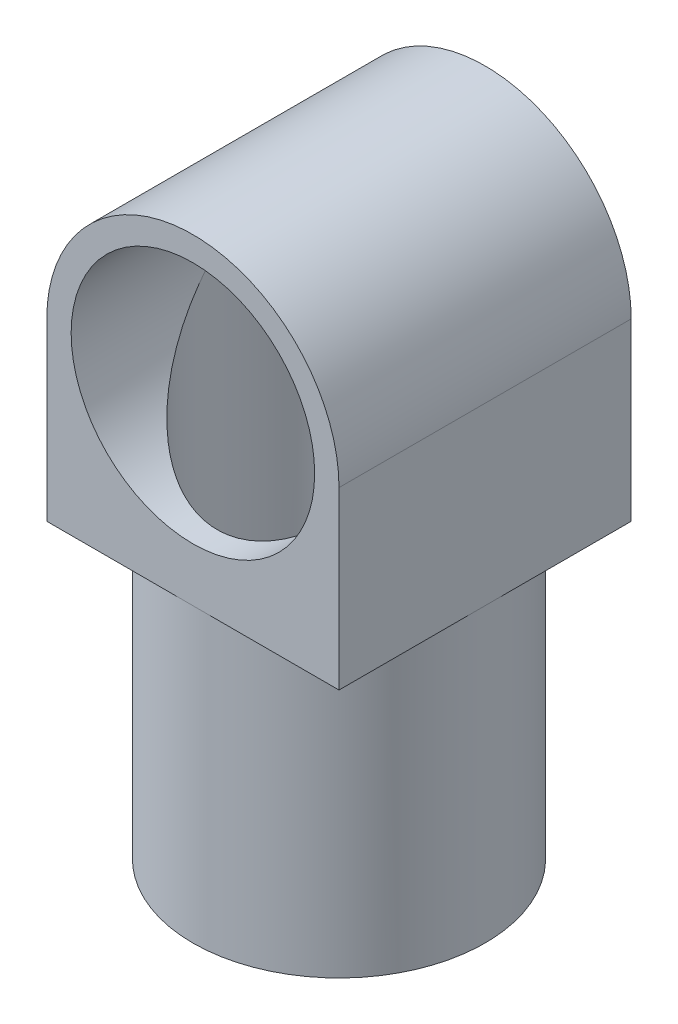
from build123d import *

# Parameters (mm, degrees)
SKETCH1_R           = 15
SKETCH1_R_2         = 12.5
BOSS_EXTRUDE2_DEPTH = 30
SKETCH3_R           = 15
SKETCH3_R_2         = 12.5
BOSS_EXTRUDE3_DEPTH = 30
SKETCH4_R           = 12.5
CUT_EXTRUDE1_DEPTH  = 18


with BuildPart() as part:
    # Sketch1 → Boss-Extrude2 (new body)
    with BuildSketch(Plane.XY):
        with BuildLine():
            ThreePointArc((15, 0), (0, -15), (-15, 0))
            Line((-15, 0), (-15, -15))
            Line((-15, -15), (-15, -18))
            Line((-15, -18), (15, -18))
            Line((15, -18), (15, 0))
        make_face()
        Circle(SKETCH1_R)
        Circle(SKETCH1_R_2, mode=Mode.SUBTRACT)
    extrude(amount=BOSS_EXTRUDE2_DEPTH)

    # Sketch3 → Boss-Extrude3 (add)
    with BuildSketch(Plane.XZ.offset(18)):
        with Locations((0, 15)):
            Circle(SKETCH3_R)
        with Locations((0, 15)):
            Circle(SKETCH3_R_2, mode=Mode.SUBTRACT)
    extrude(amount=BOSS_EXTRUDE3_DEPTH)

    # Sketch4 → Cut-Extrude1 (cut)
    with BuildSketch(Plane.XZ.offset(18)):
        with Locations((0, 15)):
            Circle(SKETCH4_R)
    extrude(amount=-CUT_EXTRUDE1_DEPTH, mode=Mode.SUBTRACT)


solid = part.part
